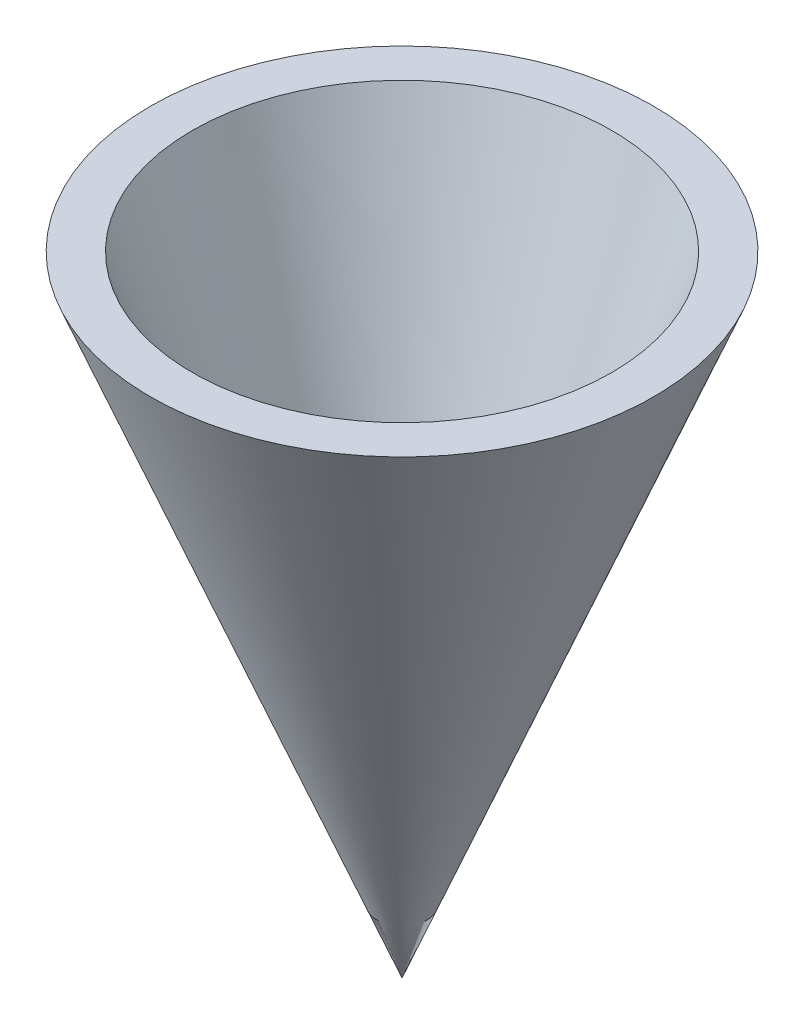
from build123d import *


with BuildPart() as part:
    # Croquis2 → Revolución1 (revolve)
    with BuildSketch(Plane.XY):
        Polygon((-10, 0), (-12, 0), (0, -30), (0, -25.464847308), (-3.023435128, -20.929694616), align=None)
    revolve(axis=Axis((0, 0, 0), (0, -1, 0)))


solid = part.part
